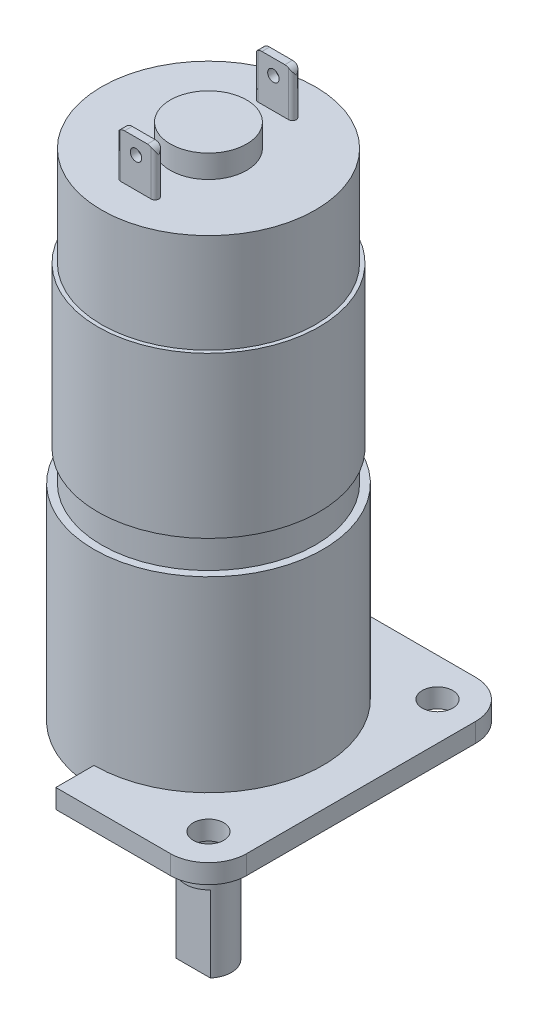
from build123d import *

# Parameters (mm, degrees)
CROQUIS1_R               = 14
MOTOR_DEPTH              = 38
CROQUIS2_R               = 5
SALIENTE_POSTERIOR_DEPTH = 3
BORNES_DEPTH             = 6
CROQUIS4_R               = 0.75
AGUJERO_BORNES_DEPTH     = 24.5
CROQUIS5_R               = 15
CAJA_REDUCTORA_DEPTH     = 24.5
CROQUIS6_R               = 2
BRIDA_DEPTH              = 2.5
CROQUIS7_R               = 6.5
SALIENTE_EJE_DEPTH       = 13.5
CROQUIS8_R               = 3
EJE_DEPTH                = 13.5
CORTE_PLANO_EJE_DEPTH    = 10
CROQUIS10_R              = 2
CORTE_BRIDA_DEPTH        = 10
SALIENTE_EXTRUIR1_START  = 4
CROQUIS11_R              = 14.5
SALIENTE_EXTRUIR1_DEPTH  = 21


with BuildPart() as part:
    # Croquis1 → Motor (new body)
    with BuildSketch(Plane(origin=(0, 0, 0), x_dir=(1, 0, 0), z_dir=(0, 1, 0))):
        Circle(CROQUIS1_R)
    extrude(amount=MOTOR_DEPTH)

    # Croquis2 → Saliente posterior (add)
    with BuildSketch(Plane(origin=(0, 38, 0), x_dir=(1, 0, 0), z_dir=(0, 1, 0))):
        Circle(CROQUIS2_R)
    extrude(amount=SALIENTE_POSTERIOR_DEPTH)

    # Croquis3 → Bornes (add)
    with BuildSketch(Plane(origin=(0, 38, 0), x_dir=(1, 0, 0), z_dir=(0, 1, 0))):
        with BuildLine():
            Line((-2, 9.5), (2, 9.5))
            ThreePointArc((2, 9.5), (2.5, 9), (2, 8.5))
            Line((2, 8.5), (-2, 8.5))
            ThreePointArc((-2, 8.5), (-2.5, 9), (-2, 9.5))
        make_face()
        with BuildLine():
            Line((-2, -9.5), (2, -9.5))
            ThreePointArc((2, -9.5), (2.5, -9), (2, -8.5))
            Line((2, -8.5), (-2, -8.5))
            ThreePointArc((-2, -8.5), (-2.5, -9), (-2, -9.5))
        make_face()
    extrude(amount=BORNES_DEPTH)

    # Croquis4 → Agujero Bornes (cut, through all)
    with BuildSketch(Plane.XY.offset(9.5)):
        with Locations((0, 42)):
            Circle(CROQUIS4_R)
        with BuildLine():
            ThreePointArc((2, 43.866025404), (2.366025404, 43.5), (2.5, 43))
            Line((2.5, 43), (2.5, 44))
            Line((2.5, 44), (2, 44))
            Line((2, 44), (2, 43.866025404))
        make_face()
        with BuildLine():
            ThreePointArc((1.5, 44), (1.758819045, 43.965925826), (2, 43.866025404))
            Line((2, 43.866025404), (2, 44))
            Line((2, 44), (1.5, 44))
        make_face()
        with BuildLine():
            Line((-2, 43.866025404), (-2, 44))
            Line((-2, 44), (-2.5, 44))
            Line((-2.5, 44), (-2.5, 43))
            ThreePointArc((-2.5, 43), (-2.366025404, 43.5), (-2, 43.866025404))
        make_face()
        with BuildLine():
            ThreePointArc((-2, 43.866025404), (-1.758819045, 43.965925826), (-1.5, 44))
            Line((-1.5, 44), (-2, 44))
            Line((-2, 44), (-2, 43.866025404))
        make_face()
    extrude(amount=-AGUJERO_BORNES_DEPTH, mode=Mode.SUBTRACT)

    # Croquis5 → Caja reductora (add)
    with BuildSketch(Plane.XZ):
        Circle(CROQUIS5_R)
    extrude(amount=CAJA_REDUCTORA_DEPTH)

    # Croquis6 → Brida (add)
    with BuildSketch(Plane.XZ.offset(24.5)):
        with BuildLine():
            Line((-15, 20), (15, 20))
            ThreePointArc((15, 20), (18.535533906, 18.535533906), (20, 15))
            Line((20, 15), (20, -15))
            ThreePointArc((20, -15), (18.535533906, -18.535533906), (15, -20))
            Line((15, -20), (-15, -20))
            ThreePointArc((-15, -20), (-18.535533906, -18.535533906), (-20, -15))
            Line((-20, -15), (-20, 15))
            ThreePointArc((-20, 15), (-18.535533906, 18.535533906), (-15, 20))
        make_face()
        with Locations((-15, 15)):
            Circle(CROQUIS6_R, mode=Mode.SUBTRACT)
        with Locations((15, 15)):
            Circle(CROQUIS6_R, mode=Mode.SUBTRACT)
        with Locations((15, -15)):
            Circle(CROQUIS6_R, mode=Mode.SUBTRACT)
        with Locations((-15, -15)):
            Circle(CROQUIS6_R, mode=Mode.SUBTRACT)
    extrude(amount=BRIDA_DEPTH)

    # Croquis7 → Saliente eje (add)
    with BuildSketch(Plane.XZ.offset(27)):
        Circle(CROQUIS7_R)
    extrude(amount=SALIENTE_EJE_DEPTH)

    # Croquis8 → Eje (add)
    with BuildSketch(Plane.XZ.offset(40.5)):
        Circle(CROQUIS8_R)
    extrude(amount=EJE_DEPTH)

    # Croquis9 → Corte Plano eje (cut)
    with BuildSketch(Plane.XZ.offset(54)):
        Polygon((-74.796206056, 2), (-2.236067977, 2), (2.236067977, 2), (74.796206056, 2), (74.796206056, 147.120276157), (-74.796206056, 147.120276157), align=None)
    extrude(amount=-CORTE_PLANO_EJE_DEPTH, mode=Mode.SUBTRACT)

    # Croquis10 → Corte Brida (cut)
    with BuildSketch(Plane(origin=(0, -24.5, 0), x_dir=(1, 0, 0), z_dir=(0, 1, 0))):
        with BuildLine():
            Line((0, 15), (0, 20))
            Line((0, 20), (-15, 20))
            ThreePointArc((-15, 20), (-18.535533906, 18.535533906), (-20, 15))
            Line((-20, 15), (-20, -15))
            ThreePointArc((-20, -15), (-18.535533906, -18.535533906), (-15, -20))
            Line((-15, -20), (0, -20))
            Line((0, -20), (0, -15))
            ThreePointArc((0, -15), (-15, 0), (0, 15))
        make_face()
        with Locations((-15, -15)):
            Circle(CROQUIS10_R, mode=Mode.SUBTRACT)
        with Locations((-15, 15)):
            Circle(CROQUIS10_R, mode=Mode.SUBTRACT)
    extrude(amount=-CORTE_BRIDA_DEPTH, mode=Mode.SUBTRACT)

    # Croquis11 → Saliente-Extruir1 (add)
    with BuildSketch(Plane(origin=(0, 0, 0), x_dir=(1, 0, 0), z_dir=(0, 1, 0)).offset(SALIENTE_EXTRUIR1_START)):
        Circle(CROQUIS11_R)
    extrude(amount=SALIENTE_EXTRUIR1_DEPTH)


solid = part.part
